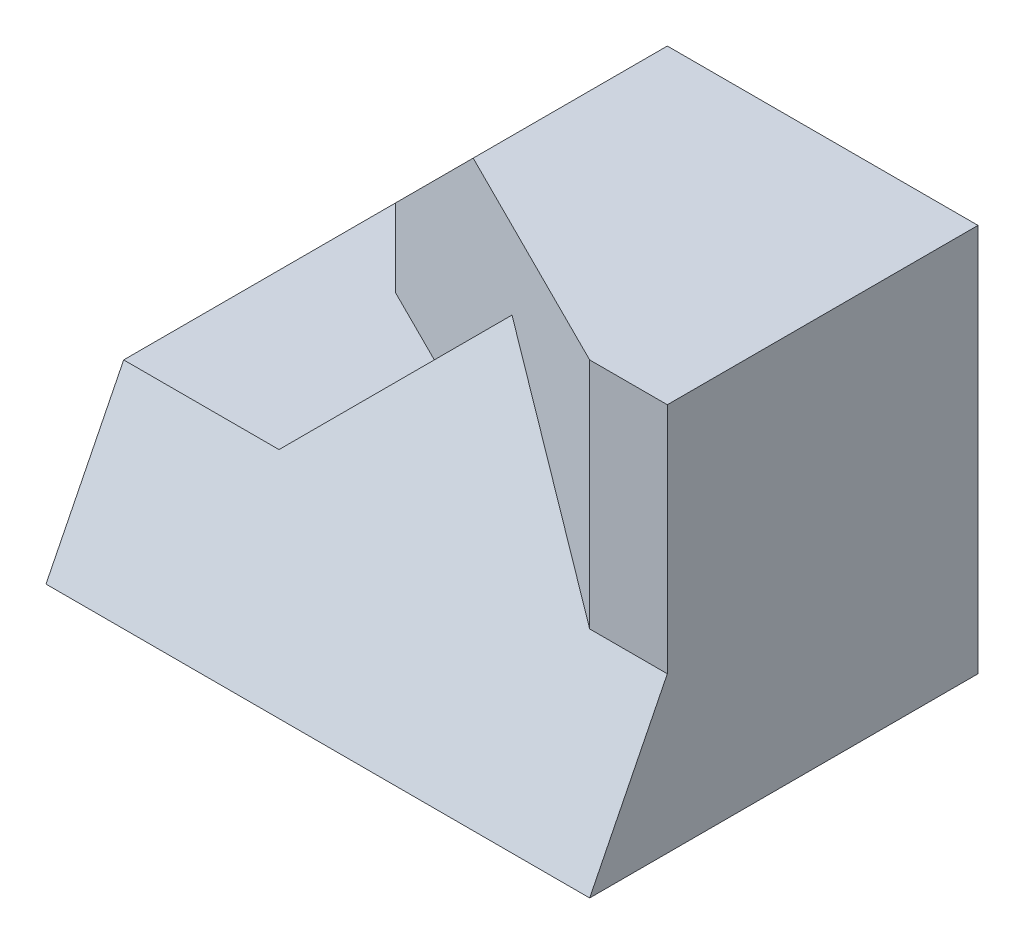
from build123d import *

# Parameters (mm, degrees)
BOSS_EXTRUDE1_DEPTH = 4
SKETCH2_W           = 7
SKETCH2_H           = 5
BOSS_EXTRUDE2_DEPTH = 2
CUT_EXTRUDE1_DEPTH  = 3
BOSS_EXTRUDE3_DEPTH = 5
CUT_EXTRUDE2_DEPTH  = 15
CUT_EXTRUDE3_DEPTH  = 15


with BuildPart() as part:
    # Sketch1 → Boss-Extrude1 (new body)
    with BuildSketch(Plane.XY):
        Polygon((-3, 0.5), (-1, 2.5), (3, 2.5), (3, -2.5), (-3, -2.5), align=None)
    extrude(amount=BOSS_EXTRUDE1_DEPTH)

    # Sketch2 → Boss-Extrude2 (add)
    with BuildSketch(Plane.XZ.offset(2.5)):
        with Locations((-0.5, 2.5)):
            Rectangle(SKETCH2_W, SKETCH2_H)
    extrude(amount=-BOSS_EXTRUDE2_DEPTH)

    # Sketch3 → Cut-Extrude1 (cut)
    with BuildSketch(Plane(origin=(0, 2.5, 0), x_dir=(1, 0, 0), z_dir=(0, 1, 0))):
        Polygon((2, -4), (-3, -1.5), (-3, -4), align=None)
    extrude(amount=-CUT_EXTRUDE1_DEPTH, mode=Mode.SUBTRACT)

    # Sketch4 → Boss-Extrude3 (add)
    with BuildSketch(Plane(origin=(0, 0, 0), x_dir=(-1, 0, 0), z_dir=(0, 0, -1))):
        Polygon((-2, -0.5), (0, 1.5), (2, -0.5), (4, -0.5), (4, -2.5), (-3, -2.5), (-3, -0.5), align=None)
    extrude(amount=-BOSS_EXTRUDE3_DEPTH)

    # Sketch5 → Cut-Extrude2 (cut)
    with BuildSketch(Plane.ZY.offset(4)):
        Polygon((5, -2.5), (4, -0.5), (5, -0.5), align=None)
    extrude(amount=-CUT_EXTRUDE2_DEPTH, mode=Mode.SUBTRACT)

    # 3DSketch3 → Cut-Extrude3 (cut, along a direction that is not the sketch's normal)
    with BuildSketch(Plane(origin=(-2, -0.5, 4), x_dir=(1, 0, 0), z_dir=(0, 0.4472135954999576, 0.8944271909999162))):
        Polygon((0, 0), (2, 2.236067977), (4, 0), align=None)
    extrude(amount=CUT_EXTRUDE3_DEPTH, dir=(0, 0, 1), mode=Mode.SUBTRACT)


solid = part.part
